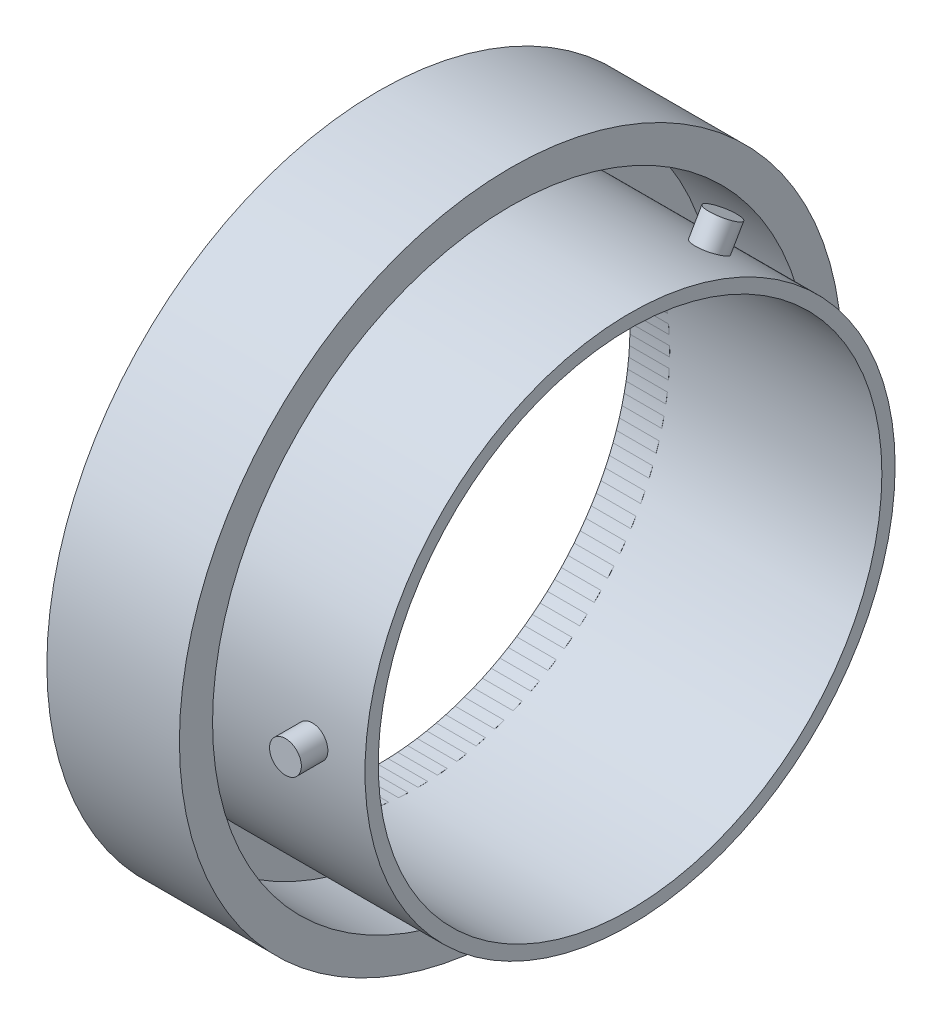
from build123d import *

# Parameters (mm, degrees)
SKETCH1_R           = 40
SKETCH1_R_2         = 38
BOSS_EXTRUDE1_DEPTH = 38
SKETCH2_R           = 2.4
BOSS_EXTRUDE3_DEPTH = 44
CIRPATTERN1_COUNT   = 3
SKETCH1_3_R         = 38
CUT_EXTRUDE2_DEPTH  = 71.56911523
SKETCH3_R           = 50
SKETCH3_R_2         = 45
BOSS_EXTRUDE4_DEPTH = 20
SKETCH3_4_R         = 45
SKETCH3_4_R_2       = 38
BOSS_EXTRUDE5_DEPTH = 6


with BuildPart() as part:
    # Sketch1 → Boss-Extrude1 (new body)
    with BuildSketch(Plane(origin=(0, 0, 0), x_dir=(0, 0, -1), z_dir=(1, 0, 0))):
        Circle(SKETCH1_R)
        Circle(SKETCH1_R_2, mode=Mode.SUBTRACT)
    extrude(amount=BOSS_EXTRUDE1_DEPTH)

    # Sketch2 → Boss-Extrude3 (add)
    with BuildSketch(Plane.XY):
        with Locations((30, 0)):
            Circle(SKETCH2_R)
    boss_extrude3 = extrude(amount=BOSS_EXTRUDE3_DEPTH)

    # CirPattern1: Boss-Extrude3 ×3 about axis
    cirpattern1_axis = Axis((38, 0, 0), (1, 0, 0))
    for i in range(1, CIRPATTERN1_COUNT):
        add(boss_extrude3.rotate(cirpattern1_axis, i * 360 / CIRPATTERN1_COUNT))

    # Sketch1_3 → Cut-Extrude2 (cut, through all)
    with BuildSketch(Plane(origin=(0, 0, 0), x_dir=(0, 0, -1), z_dir=(1, 0, 0))):
        Circle(SKETCH1_3_R)
    extrude(amount=CUT_EXTRUDE2_DEPTH, mode=Mode.SUBTRACT)


with BuildPart() as body_2:
    # Sketch3 → Boss-Extrude4 (new body)
    with BuildSketch(Plane.ZY):
        Circle(SKETCH3_R)
        Circle(SKETCH3_R_2, mode=Mode.SUBTRACT)
    extrude(amount=-BOSS_EXTRUDE4_DEPTH)

    # Sketch3_4 → Boss-Extrude5 (add)
    with BuildSketch(Plane.ZY):
        Circle(SKETCH3_4_R)
        Circle(SKETCH3_4_R_2, mode=Mode.SUBTRACT)
    extrude(amount=-BOSS_EXTRUDE5_DEPTH)


solid = Compound([part.part, body_2.part])
